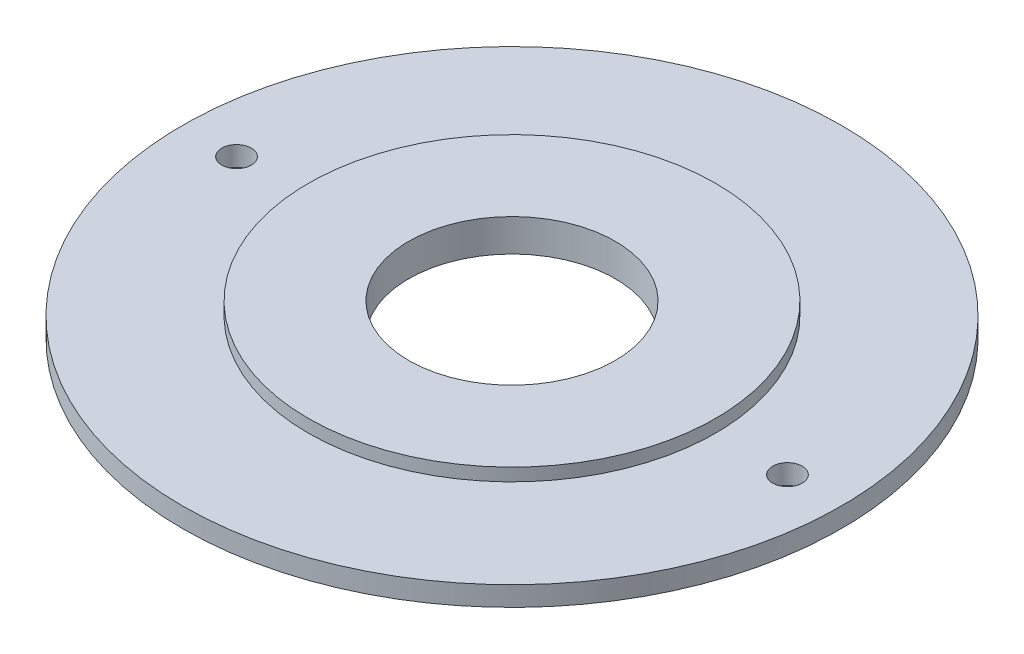
from build123d import *

# Parameters (mm, degrees)
SKETCH_1_R          = 16.75
EXTRUDE_1_DEPTH     = 1
SKETCH_2_R          = 10.35
EXTRUDE_2_DEPTH     = 0.65
SKETCH_3_R          = 5.25
CUT_EXTRUDE_1_DEPTH = 2.65
SKETCH_4_R          = 0.7499985
CUT_EXTRUDE_2_DEPTH = 2.65


with BuildPart() as part:
    # Эскиз1 → Бобышка-Вытянуть1 (new body)
    with BuildSketch(Plane(origin=(0, 0, 0), x_dir=(1, 0, 0), z_dir=(0, 1, 0))):
        Circle(SKETCH_1_R)
    extrude(amount=EXTRUDE_1_DEPTH)

    # Эскиз2 → Бобышка-Вытянуть2 (add)
    with BuildSketch(Plane(origin=(0, 1, 0), x_dir=(1, 0, 0), z_dir=(0, 1, 0))):
        Circle(SKETCH_2_R)
    extrude(amount=EXTRUDE_2_DEPTH)

    # Эскиз3 → Вырез-Вытянуть1 (cut, through all)
    with BuildSketch(Plane(origin=(0, 1.65, 0), x_dir=(1, 0, 0), z_dir=(0, 1, 0))):
        Circle(SKETCH_3_R)
    extrude(amount=-CUT_EXTRUDE_1_DEPTH, mode=Mode.SUBTRACT)

    # Эскиз4 → Вырез-Вытянуть2 (cut, through all)
    with BuildSketch(Plane(origin=(0, 0, 0), x_dir=(-1, 0, 0), z_dir=(0, -1, 0))):
        with Locations((-14.0000228, 0)):
            Circle(SKETCH_4_R)
        with Locations((13.999972, 0)):
            Circle(SKETCH_4_R)
    extrude(amount=-CUT_EXTRUDE_2_DEPTH, mode=Mode.SUBTRACT)


solid = part.part
